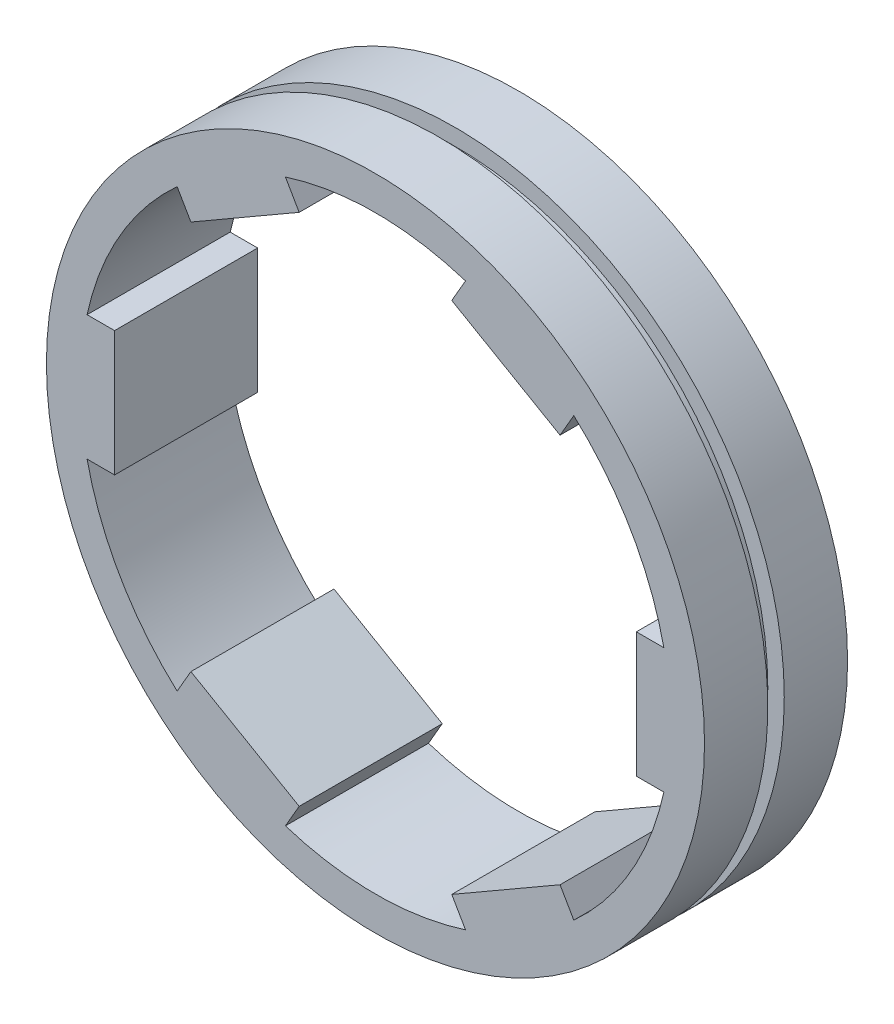
from build123d import *

# Parameters (mm, degrees)
SKETCH2_R           = 23
SKETCH2_R_2         = 20.625
BOSS_EXTRUDE1_DEPTH = 10
SKETCH3_W           = 2.53
SKETCH3_H           = 8.74
BOSS_EXTRUDE2_DEPTH = 10
CIRPATTERN1_COUNT   = 6
SKETCH4_W           = 1.15
SKETCH4_H           = 2.3


with BuildPart() as part:
    # Sketch2 → Boss-Extrude1 (new body)
    with BuildSketch(Plane.XY):
        Circle(SKETCH2_R)
        Circle(SKETCH2_R_2, mode=Mode.SUBTRACT)
    extrude(amount=BOSS_EXTRUDE1_DEPTH)

    # Sketch3 → Boss-Extrude2 (add)
    with BuildSketch(Plane.XY):
        with Locations((-19.5, 0)):
            Rectangle(SKETCH3_W, SKETCH3_H)
    boss_extrude2 = extrude(amount=BOSS_EXTRUDE2_DEPTH)

    # CirPattern1: Boss-Extrude2 ×6 about axis
    cirpattern1_axis = Axis((0, 0, 0), (0, 0, 1))
    for i in range(1, CIRPATTERN1_COUNT):
        add(boss_extrude2.rotate(cirpattern1_axis, i * 360 / CIRPATTERN1_COUNT))

    # Sketch4 → Cut-Revolve1 (revolve, cut)
    with BuildSketch(Plane(origin=(0, 0, 0), x_dir=(0, 0, -1), z_dir=(1, 0, 0))):
        with Locations((-5, 23)):
            Rectangle(SKETCH4_W, SKETCH4_H)
    revolve(axis=Axis((0, 0, 10), (0, 0, -1)), mode=Mode.SUBTRACT)


solid = part.part
